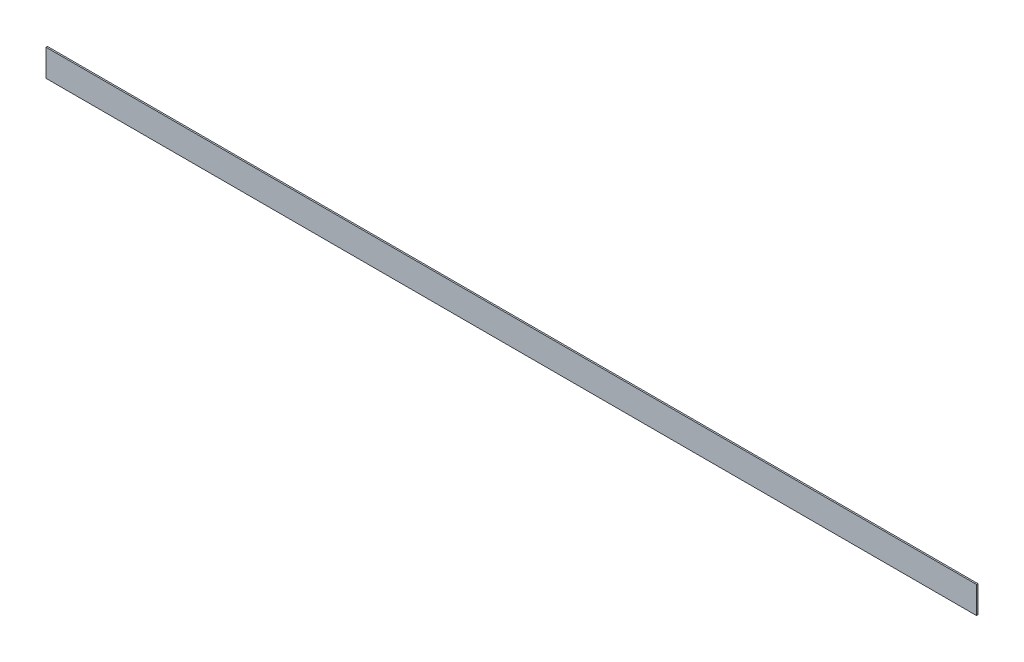
from build123d import *

# Parameters (mm, degrees)
SKETCH1_W           = 16560.8
SKETCH1_H           = 480
BOSS_EXTRUDE1_DEPTH = 25.4


with BuildPart() as part:
    # Sketch1 → Boss-Extrude1 (new body)
    with BuildSketch(Plane.XY):
        with Locations((8280.4, -240)):
            Rectangle(SKETCH1_W, SKETCH1_H)
    extrude(amount=BOSS_EXTRUDE1_DEPTH)


solid = part.part
